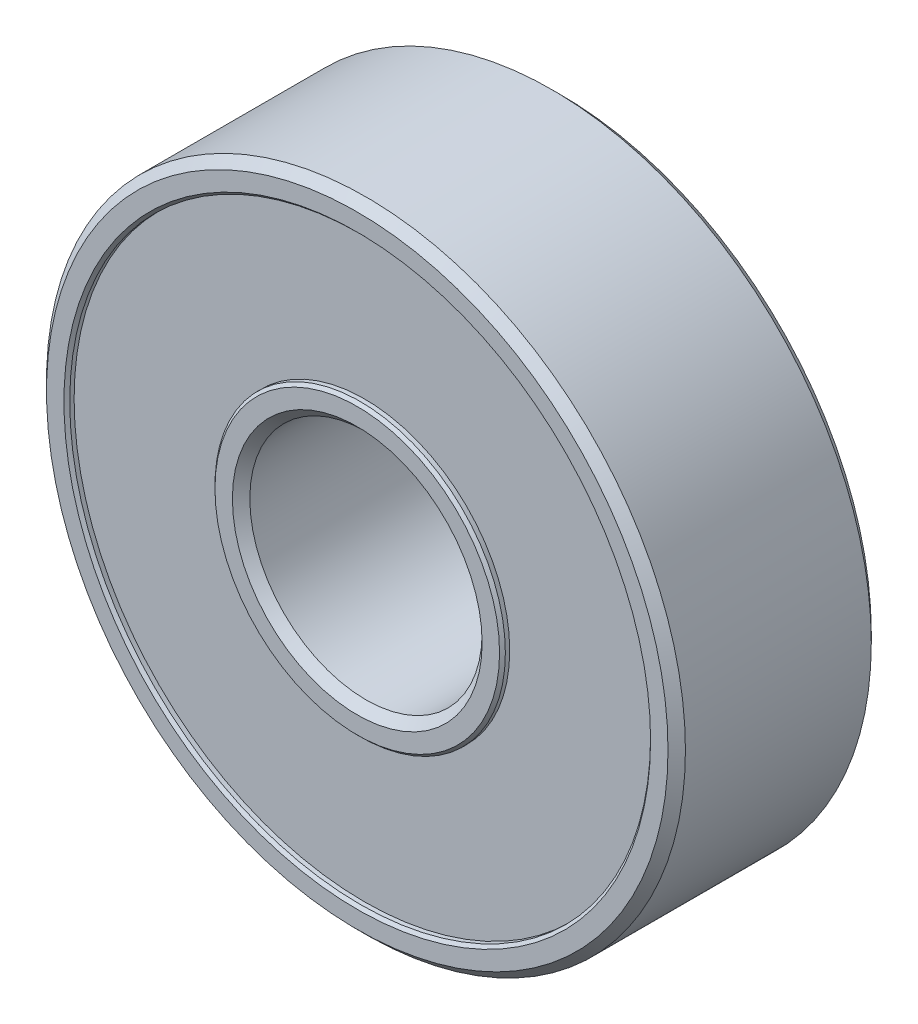
from build123d import *

# Parameters (mm, degrees)
SKETCH1_R             = 11
SKETCH1_R_2           = 10
BOSS_EXTRUDE1_DEPTH   = 3.5
SKETCH1_R_3           = 5
SKETCH1_R_4           = 4
BOSS_EXTRUDE1_2_DEPTH = 3.5
SKETCH1_3_R           = 10
SKETCH1_3_R_2         = 5
BOSS_EXTRUDE2_DEPTH   = 3.25
CHAMFER1_SIZE         = 0.3
CHAMFER2_SIZE         = 0.1


with BuildPart() as part:
    # Sketch1 → Boss-Extrude1 (new, symmetric)
    with BuildSketch(Plane.XY):
        Circle(SKETCH1_R)
        Circle(SKETCH1_R_2, mode=Mode.SUBTRACT)
    extrude(amount=BOSS_EXTRUDE1_DEPTH, both=True)



with BuildPart() as body_2:
    # Sketch1 → Boss-Extrude1 2 (new, symmetric)
    with BuildSketch(Plane.XY):
        Circle(SKETCH1_R_3)
        Circle(SKETCH1_R_4, mode=Mode.SUBTRACT)
    extrude(amount=BOSS_EXTRUDE1_2_DEPTH, both=True)


with BuildPart() as part_1:
    add(part.part)

    add(body_2.part)  # Boss-Extrude2 merges body 2
    # Sketch1_3 → Boss-Extrude2 (add, symmetric)
    with BuildSketch(Plane.XY):
        Circle(SKETCH1_3_R)
        Circle(SKETCH1_3_R_2, mode=Mode.SUBTRACT)
    extrude(amount=BOSS_EXTRUDE2_DEPTH, both=True)

    # Chamfer1
    chamfer1_edges = [part_1.edges().sort_by_distance(p)[0] for p in [
        (-4, 0, -3.5),
        (-11, 0, 3.5),
        (-11, 0, -3.5),
        (-4, 0, 3.5),
    ]]
    chamfer(chamfer1_edges, length=CHAMFER1_SIZE)

    # Chamfer2
    chamfer2_edges = [part_1.edges().sort_by_distance(p)[0] for p in [
        (-10, 0, 3.5),
        (-5, 0, 3.5),
        (-5, 0, -3.5),
        (-10, 0, -3.25),
    ]]
    chamfer(chamfer2_edges, length=CHAMFER2_SIZE)


solid = part_1.part
